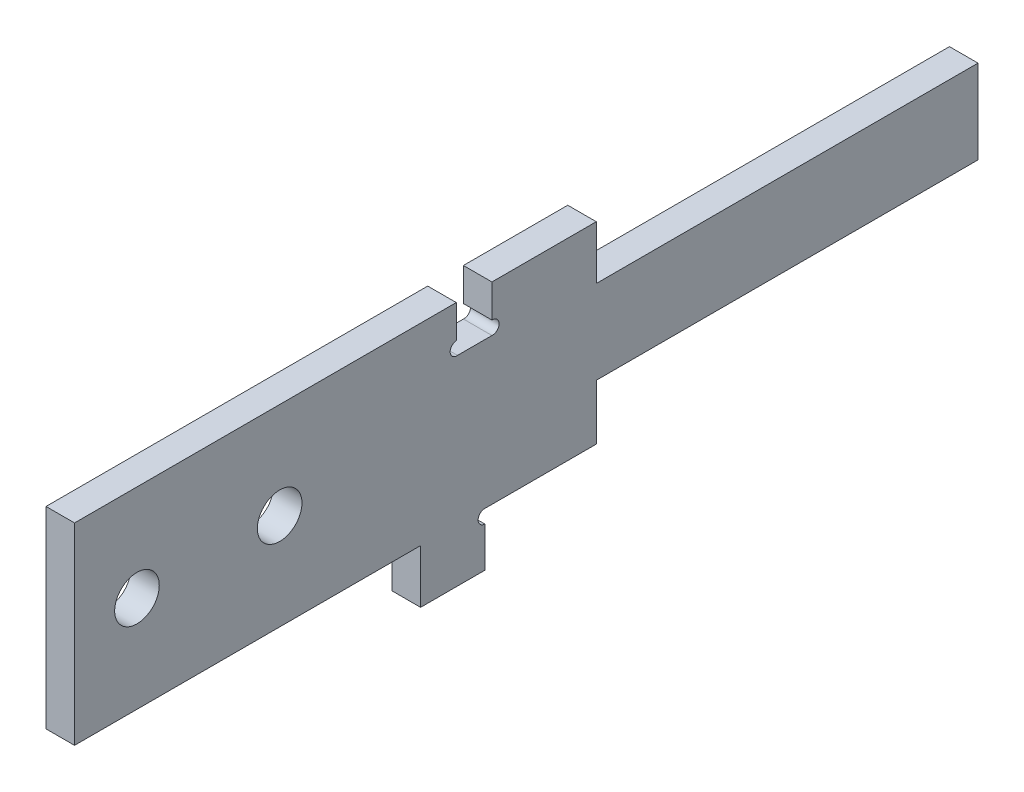
from build123d import *

# Parameters (mm, degrees)
SZKIC1_W                    = 1.6
SZKIC1_H                    = 10.8
DODANIE_WYCI_GNI_CIE1_DEPTH = 60
SZKIC2_R                    = 1.25
WYTNIJ_WYCI_GNI_CIE1_DEPTH  = 60
SZKIC3_W                    = 1.6
SZKIC3_H                    = 2
WYTNIJ_WYCI_GNI_CIE2_DEPTH  = 2.6
SZKIC4_W                    = 1.6
SZKIC4_H                    = 2
DODANIE_WYCI_GNI_CIE2_DEPTH = 3
WYTNIJ_WYCI_GNI_CIE3_START  = -30.75
SZKIC6_W                    = 1.6
SZKIC6_H                    = 3
SZKIC6_H_2                  = 3.1
WYTNIJ_WYCI_GNI_CIE3_DEPTH  = 30.75
SZKIC7_W                    = 1.6
SZKIC7_H                    = 4.7
WYTNIJ_WYCI_GNI_CIE4_DEPTH  = 9.35
SZKIC8_W                    = 1.6
SZKIC8_H                    = 1.6
DODANIE_WYCI_GNI_CIE3_DEPTH = 3
SZKIC9_R                    = 0.375
SZKIC9_R_2                  = 0.37655367
SZKIC9_R_3                  = 0.375938448
WYTNIJ_WYCI_GNI_CIE5_DEPTH  = 1.6


with BuildPart() as part:
    # Szkic1 → Dodanie-wyciągnięcie1 (new body)
    with BuildSketch(Plane.XY):
        with Locations((-22.216876634, 9.987687188)):
            Rectangle(SZKIC1_W, SZKIC1_H)
    extrude(amount=DODANIE_WYCI_GNI_CIE1_DEPTH)

    # Szkic2 → Wytnij-wyciągnięcie1 (cut)
    with BuildSketch(Plane(origin=(-21.416876634, 0, 0), x_dir=(0, 0, -1), z_dir=(1, 0, 0))):
        with Locations((-56.5, 9.987687188)):
            Circle(SZKIC2_R)
        with Locations((-48.5, 9.987687188)):
            Circle(SZKIC2_R)
    extrude(amount=-WYTNIJ_WYCI_GNI_CIE1_DEPTH, mode=Mode.SUBTRACT)

    # Szkic3 → Wytnij-wyciągnięcie2 (cut)
    with BuildSketch(Plane(origin=(0, 15.387687188, 0), x_dir=(1, 0, 0), z_dir=(0, 1, 0))):
        with Locations((-22.216876634, -37.6)):
            Rectangle(SZKIC3_W, SZKIC3_H)
    extrude(amount=-WYTNIJ_WYCI_GNI_CIE2_DEPTH, mode=Mode.SUBTRACT)

    # Szkic4 → Dodanie-wyciągnięcie2 (add)
    with BuildSketch(Plane.XZ.offset(-4.587687188)):
        with Locations((-22.216876634, 39.6)):
            Rectangle(SZKIC4_W, SZKIC4_H)
    extrude(amount=DODANIE_WYCI_GNI_CIE2_DEPTH)

    # Szkic6 → Wytnij-wyciągnięcie3 (cut)
    with BuildSketch(Plane(origin=(0, 0, 0), x_dir=(-1, 0, 0), z_dir=(0, 0, -1)).offset(WYTNIJ_WYCI_GNI_CIE3_START)):
        with Locations((22.216876634, 13.887687188)):
            Rectangle(SZKIC6_W, SZKIC6_H)
        with Locations((22.216876634, 6.137687188)):
            Rectangle(SZKIC6_W, SZKIC6_H_2)
    extrude(amount=WYTNIJ_WYCI_GNI_CIE3_DEPTH, mode=Mode.SUBTRACT)

    # Szkic7 → Wytnij-wyciągnięcie4 (cut)
    with BuildSketch(Plane(origin=(0, 0, 0), x_dir=(-1, 0, 0), z_dir=(0, 0, -1))):
        with Locations((22.216876634, 10.037687188)):
            Rectangle(SZKIC7_W, SZKIC7_H)
    extrude(amount=-WYTNIJ_WYCI_GNI_CIE4_DEPTH, mode=Mode.SUBTRACT)

    # Szkic8 → Dodanie-wyciągnięcie3 (add)
    with BuildSketch(Plane.XZ.offset(-4.587687188)):
        with Locations((-22.216876634, 37.8)):
            Rectangle(SZKIC8_W, SZKIC8_H)
    extrude(amount=DODANIE_WYCI_GNI_CIE3_DEPTH)

    # Szkic9 → Wytnij-wyciągnięcie5 (cut)
    with BuildSketch(Plane.ZY.offset(23.016876634)):
        with Locations((37, 4.212687188)):
            Circle(SZKIC9_R)
        with Locations((38.565828862, 13.162687188)):
            Circle(SZKIC9_R_2)
        with Locations((36.573453505, 13.162687188)):
            Circle(SZKIC9_R_3)
    extrude(amount=-WYTNIJ_WYCI_GNI_CIE5_DEPTH, mode=Mode.SUBTRACT)


solid = part.part
